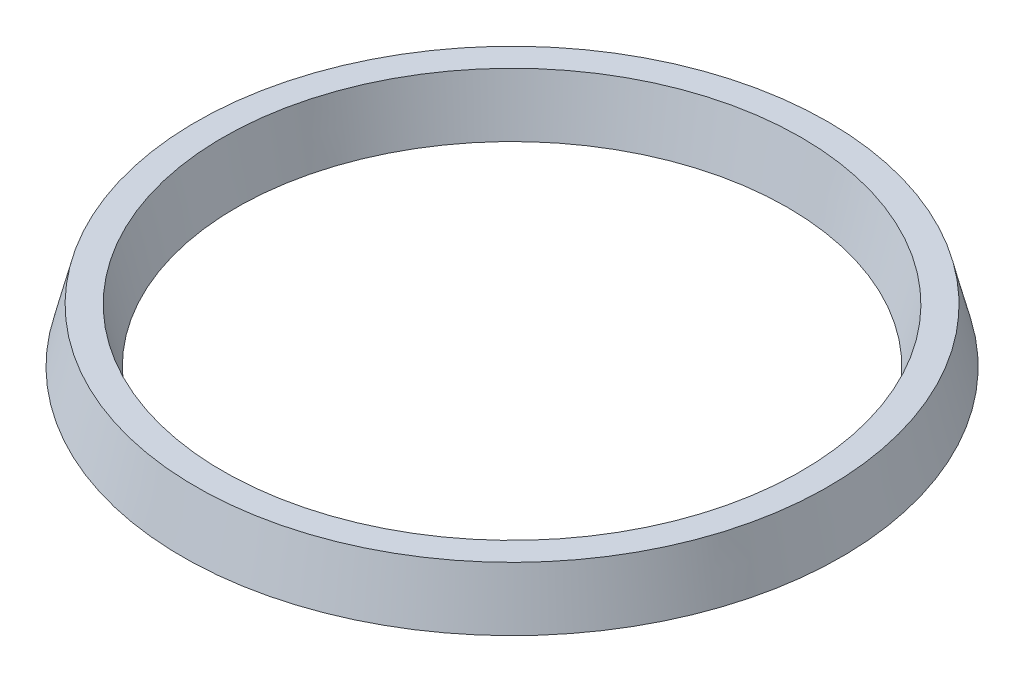
from build123d import *


with BuildPart() as part:
    # Sketch1 → Revolve1 (revolve)
    with BuildSketch(Plane.XY):
        with BuildLine():
            Line((3, 6), (-3, 6))
            Line((-3, 6), (-6, -6))
            Line((-6, -6), (-3, -6))
            Line((-3, -6), (-1.863803438, -1.45521375))
            ThreePointArc((-1.863803438, -1.45521375), (0, 0), (1.863803438, -1.45521375))
            Line((1.863803438, -1.45521375), (3, -6))
            Line((3, -6), (6, -6))
            Line((6, -6), (3, 6))
        make_face()
    revolve(axis=Axis((-67.31, 0, 0), (0, 1, 0)))


solid = part.part
